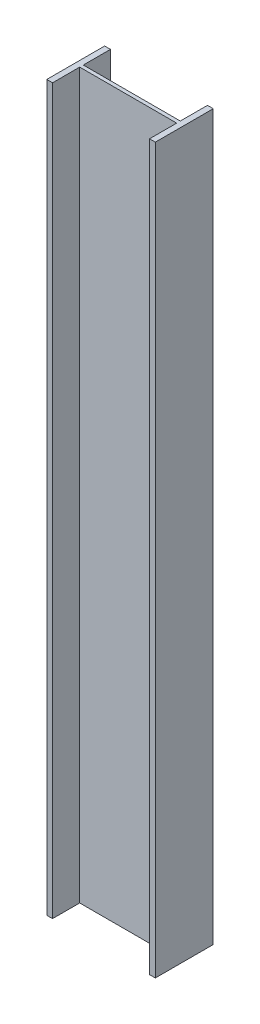
from build123d import *

# Parameters (mm, degrees)
BOSS_EXTRUDE1_DEPTH = 1000


with BuildPart() as part:
    # Sketch1 → Boss-Extrude1 (new body)
    with BuildSketch(Plane(origin=(0, 0, 0), x_dir=(1, 0, 0), z_dir=(0, 1, 0))):
        Polygon((-67, 2.5), (-67, 40), (-75, 40), (-75, -40), (-67, -40), (-67, -2.5), (67, -2.5), (67, -40), (75, -40), (75, 40), (67, 40), (67, 2.5), align=None)
    extrude(amount=BOSS_EXTRUDE1_DEPTH)


solid = part.part
